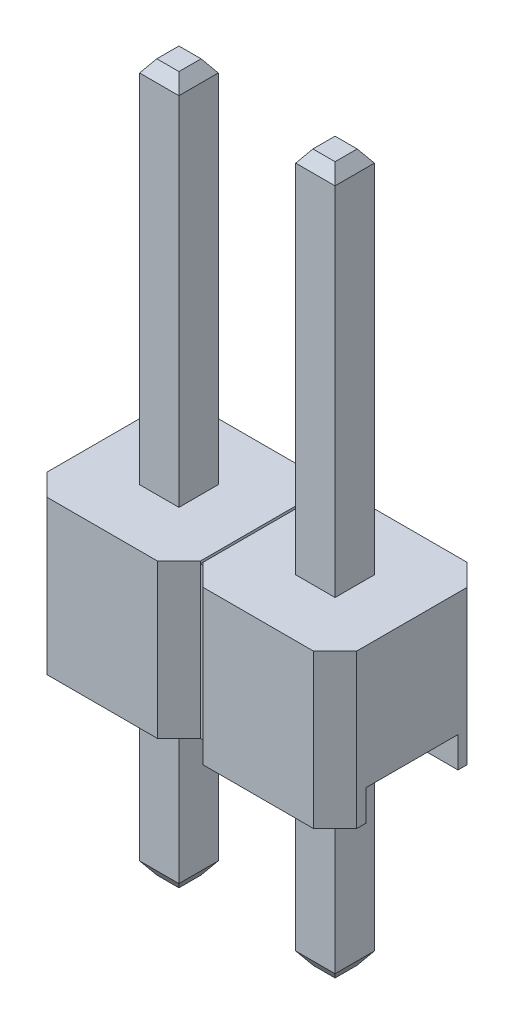
from build123d import *
from OCP.BRepFilletAPI import BRepFilletAPI_MakeChamfer

# Parameters (mm, degrees)
BOSS_EXTRUDE1_DEPTH         = 2.5
SKETCH2_W                   = 5.04
SKETCH2_H                   = 1.5
CUT_EXTRUDE1_DEPTH          = 0.5
SKETCH4_W                   = 0.04
SKETCH4_H                   = 1.8
CUT_EXTRUDE2_DEPTH          = 0.04
BOSS_EXTRUDE2_START         = -5.5
SKETCH3_W                   = 0.64
SKETCH3_H                   = 0.64
BOSS_EXTRUDE2_DEPTH         = 11.5
CHAMFER1_SIZE               = 0.2
CHAMFER1_SIZE2              = 0.140041508
LPATTERN1_COUNT             = 2
LPATTERN1_PITCH             = 2.54
CHAMFER1_OF_LPATTERN1_SIZE  = 0.2
CHAMFER1_OF_LPATTERN1_SIZE2 = 0.140041508


with BuildPart() as part:
    # Sketch1 → Boss-Extrude1 (new body)
    with BuildSketch(Plane(origin=(0, 0, 0), x_dir=(1, 0, 0), z_dir=(0, 1, 0))):
        Polygon((0, 2.15), (0.35, 2.5), (2.15, 2.5), (2.5, 2.15), (2.54, 2.15), (2.89, 2.5), (4.69, 2.5), (5.04, 2.15), (5.04, 0.35), (4.69, 0), (2.89, 0), (2.54, 0.35), (2.5, 0.35), (2.15, 0), (0.35, 0), (0, 0.35), align=None)
    extrude(amount=BOSS_EXTRUDE1_DEPTH)

    # Sketch2 → Cut-Extrude1 (cut)
    with BuildSketch(Plane.XZ):
        with Locations((2.52, -1.25)):
            Rectangle(SKETCH2_W, SKETCH2_H)
    extrude(amount=-CUT_EXTRUDE1_DEPTH, mode=Mode.SUBTRACT)

    # Sketch4 → Cut-Extrude2 (cut)
    with BuildSketch(Plane(origin=(0, 2.5, 0), x_dir=(1, 0, 0), z_dir=(0, 1, 0))):
        with Locations((5.06, 1.25)):
            Rectangle(SKETCH4_W, SKETCH4_H)
        with Locations((2.52, 1.25)):
            Rectangle(SKETCH4_W, SKETCH4_H)
        with Locations((7.6, 1.25)):
            Rectangle(SKETCH4_W, SKETCH4_H)
        with Locations((10.14, 1.25)):
            Rectangle(SKETCH4_W, SKETCH4_H)
        with Locations((12.68, 1.25)):
            Rectangle(SKETCH4_W, SKETCH4_H)
        with Locations((15.22, 1.25)):
            Rectangle(SKETCH4_W, SKETCH4_H)
        with Locations((17.76, 1.25)):
            Rectangle(SKETCH4_W, SKETCH4_H)
    extrude(amount=-CUT_EXTRUDE2_DEPTH, mode=Mode.SUBTRACT)

    # Sketch3 → Boss-Extrude2 (add)
    with BuildSketch(Plane(origin=(0, 2.5, 0), x_dir=(1, 0, 0), z_dir=(0, 1, 0)).offset(BOSS_EXTRUDE2_START)):
        with Locations((1.25, 1.25)):
            Rectangle(SKETCH3_W, SKETCH3_H)
    boss_extrude2 = extrude(amount=BOSS_EXTRUDE2_DEPTH)

    # Chamfer1: one chamfer whose edges measure the first distance from different faces: ONE call of the kernel's chamfer builder (chamfer() names one face for all edges)
    chamfer1_edges_1 = [part.edges().sort_by_distance(p)[0] for p in [
        (1.57, -3, -1.25),
    ]]
    chamfer1_side_1 = [part.faces().sort_by_distance(p)[0] for p in [
        (1.57, -1.25, -1.25),
    ]]
    chamfer1_edges_2 = [part.edges().sort_by_distance(p)[0] for p in [
        (1.25, -3, -0.93),
    ]]
    chamfer1_side_2 = [part.faces().sort_by_distance(p)[0] for p in [
        (1.25, -1.25, -0.93),
    ]]
    chamfer1_edges_3 = [part.edges().sort_by_distance(p)[0] for p in [
        (0.93, -3, -1.25),
    ]]
    chamfer1_side_3 = [part.faces().sort_by_distance(p)[0] for p in [
        (0.93, -1.25, -1.25),
    ]]
    chamfer1_edges_4 = [part.edges().sort_by_distance(p)[0] for p in [
        (1.25, -3, -1.57),
    ]]
    chamfer1_side_4 = [part.faces().sort_by_distance(p)[0] for p in [
        (1.25, -1.25, -1.57),
    ]]
    chamfer1_edges_5 = [part.edges().sort_by_distance(p)[0] for p in [
        (1.57, 8.5, -1.25),
    ]]
    chamfer1_side_5 = [part.faces().sort_by_distance(p)[0] for p in [
        (1.57, 5.5, -1.25),
    ]]
    chamfer1_edges_6 = [part.edges().sort_by_distance(p)[0] for p in [
        (1.25, 8.5, -1.57),
    ]]
    chamfer1_side_6 = [part.faces().sort_by_distance(p)[0] for p in [
        (1.25, 5.5, -1.57),
    ]]
    chamfer1_edges_7 = [part.edges().sort_by_distance(p)[0] for p in [
        (0.93, 8.5, -1.25),
    ]]
    chamfer1_side_7 = [part.faces().sort_by_distance(p)[0] for p in [
        (0.93, 5.5, -1.25),
    ]]
    chamfer1_edges_8 = [part.edges().sort_by_distance(p)[0] for p in [
        (1.25, 8.5, -0.93),
    ]]
    chamfer1_side_8 = [part.faces().sort_by_distance(p)[0] for p in [
        (1.25, 5.5, -0.93),
    ]]
    chamfer1 = BRepFilletAPI_MakeChamfer(part.part.solid().wrapped)
    for e in chamfer1_edges_1:
        chamfer1.Add(CHAMFER1_SIZE, CHAMFER1_SIZE2, e.wrapped, chamfer1_side_1[0].wrapped)  # the first distance lies on this face
    for e in chamfer1_edges_2:
        chamfer1.Add(CHAMFER1_SIZE, CHAMFER1_SIZE2, e.wrapped, chamfer1_side_2[0].wrapped)  # the first distance lies on this face
    for e in chamfer1_edges_3:
        chamfer1.Add(CHAMFER1_SIZE, CHAMFER1_SIZE2, e.wrapped, chamfer1_side_3[0].wrapped)  # the first distance lies on this face
    for e in chamfer1_edges_4:
        chamfer1.Add(CHAMFER1_SIZE, CHAMFER1_SIZE2, e.wrapped, chamfer1_side_4[0].wrapped)  # the first distance lies on this face
    for e in chamfer1_edges_5:
        chamfer1.Add(CHAMFER1_SIZE, CHAMFER1_SIZE2, e.wrapped, chamfer1_side_5[0].wrapped)  # the first distance lies on this face
    for e in chamfer1_edges_6:
        chamfer1.Add(CHAMFER1_SIZE, CHAMFER1_SIZE2, e.wrapped, chamfer1_side_6[0].wrapped)  # the first distance lies on this face
    for e in chamfer1_edges_7:
        chamfer1.Add(CHAMFER1_SIZE, CHAMFER1_SIZE2, e.wrapped, chamfer1_side_7[0].wrapped)  # the first distance lies on this face
    for e in chamfer1_edges_8:
        chamfer1.Add(CHAMFER1_SIZE, CHAMFER1_SIZE2, e.wrapped, chamfer1_side_8[0].wrapped)  # the first distance lies on this face
    add(Compound.cast(chamfer1.Shape()), mode=Mode.REPLACE)

    # LPattern1: Boss-Extrude2 ×2
    with Locations(*[(i * LPATTERN1_PITCH, 0, 0) for i in range(1, LPATTERN1_COUNT)]):
        add(boss_extrude2)

    # Chamfer1 of LPattern1: one chamfer whose edges measure the first distance from different faces: ONE call of the kernel's chamfer builder (chamfer() names one face for all edges)
    chamfer1_of_lpattern1_edges_1 = [part.edges().sort_by_distance(p)[0] for p in [
        (4.11, -3, -1.25),
    ]]
    chamfer1_of_lpattern1_side_1 = [part.faces().sort_by_distance(p)[0] for p in [
        (4.11, -1.25, -1.25),
    ]]
    chamfer1_of_lpattern1_edges_2 = [part.edges().sort_by_distance(p)[0] for p in [
        (3.79, -3, -0.93),
    ]]
    chamfer1_of_lpattern1_side_2 = [part.faces().sort_by_distance(p)[0] for p in [
        (3.79, -1.25, -0.93),
    ]]
    chamfer1_of_lpattern1_edges_3 = [part.edges().sort_by_distance(p)[0] for p in [
        (3.47, -3, -1.25),
    ]]
    chamfer1_of_lpattern1_side_3 = [part.faces().sort_by_distance(p)[0] for p in [
        (3.47, -1.25, -1.25),
    ]]
    chamfer1_of_lpattern1_edges_4 = [part.edges().sort_by_distance(p)[0] for p in [
        (3.79, -3, -1.57),
    ]]
    chamfer1_of_lpattern1_side_4 = [part.faces().sort_by_distance(p)[0] for p in [
        (3.79, -1.25, -1.57),
    ]]
    chamfer1_of_lpattern1_edges_5 = [part.edges().sort_by_distance(p)[0] for p in [
        (4.11, 8.5, -1.25),
    ]]
    chamfer1_of_lpattern1_side_5 = [part.faces().sort_by_distance(p)[0] for p in [
        (4.11, 5.5, -1.25),
    ]]
    chamfer1_of_lpattern1_edges_6 = [part.edges().sort_by_distance(p)[0] for p in [
        (3.79, 8.5, -1.57),
    ]]
    chamfer1_of_lpattern1_side_6 = [part.faces().sort_by_distance(p)[0] for p in [
        (3.79, 5.5, -1.57),
    ]]
    chamfer1_of_lpattern1_edges_7 = [part.edges().sort_by_distance(p)[0] for p in [
        (3.47, 8.5, -1.25),
    ]]
    chamfer1_of_lpattern1_side_7 = [part.faces().sort_by_distance(p)[0] for p in [
        (3.47, 5.5, -1.25),
    ]]
    chamfer1_of_lpattern1_edges_8 = [part.edges().sort_by_distance(p)[0] for p in [
        (3.79, 8.5, -0.93),
    ]]
    chamfer1_of_lpattern1_side_8 = [part.faces().sort_by_distance(p)[0] for p in [
        (3.79, 5.5, -0.93),
    ]]
    chamfer1_of_lpattern1 = BRepFilletAPI_MakeChamfer(part.part.solid().wrapped)
    for e in chamfer1_of_lpattern1_edges_1:
        chamfer1_of_lpattern1.Add(CHAMFER1_OF_LPATTERN1_SIZE, CHAMFER1_OF_LPATTERN1_SIZE2, e.wrapped, chamfer1_of_lpattern1_side_1[0].wrapped)  # the first distance lies on this face
    for e in chamfer1_of_lpattern1_edges_2:
        chamfer1_of_lpattern1.Add(CHAMFER1_OF_LPATTERN1_SIZE, CHAMFER1_OF_LPATTERN1_SIZE2, e.wrapped, chamfer1_of_lpattern1_side_2[0].wrapped)  # the first distance lies on this face
    for e in chamfer1_of_lpattern1_edges_3:
        chamfer1_of_lpattern1.Add(CHAMFER1_OF_LPATTERN1_SIZE, CHAMFER1_OF_LPATTERN1_SIZE2, e.wrapped, chamfer1_of_lpattern1_side_3[0].wrapped)  # the first distance lies on this face
    for e in chamfer1_of_lpattern1_edges_4:
        chamfer1_of_lpattern1.Add(CHAMFER1_OF_LPATTERN1_SIZE, CHAMFER1_OF_LPATTERN1_SIZE2, e.wrapped, chamfer1_of_lpattern1_side_4[0].wrapped)  # the first distance lies on this face
    for e in chamfer1_of_lpattern1_edges_5:
        chamfer1_of_lpattern1.Add(CHAMFER1_OF_LPATTERN1_SIZE, CHAMFER1_OF_LPATTERN1_SIZE2, e.wrapped, chamfer1_of_lpattern1_side_5[0].wrapped)  # the first distance lies on this face
    for e in chamfer1_of_lpattern1_edges_6:
        chamfer1_of_lpattern1.Add(CHAMFER1_OF_LPATTERN1_SIZE, CHAMFER1_OF_LPATTERN1_SIZE2, e.wrapped, chamfer1_of_lpattern1_side_6[0].wrapped)  # the first distance lies on this face
    for e in chamfer1_of_lpattern1_edges_7:
        chamfer1_of_lpattern1.Add(CHAMFER1_OF_LPATTERN1_SIZE, CHAMFER1_OF_LPATTERN1_SIZE2, e.wrapped, chamfer1_of_lpattern1_side_7[0].wrapped)  # the first distance lies on this face
    for e in chamfer1_of_lpattern1_edges_8:
        chamfer1_of_lpattern1.Add(CHAMFER1_OF_LPATTERN1_SIZE, CHAMFER1_OF_LPATTERN1_SIZE2, e.wrapped, chamfer1_of_lpattern1_side_8[0].wrapped)  # the first distance lies on this face
    add(Compound.cast(chamfer1_of_lpattern1.Shape()), mode=Mode.REPLACE)


solid = part.part
